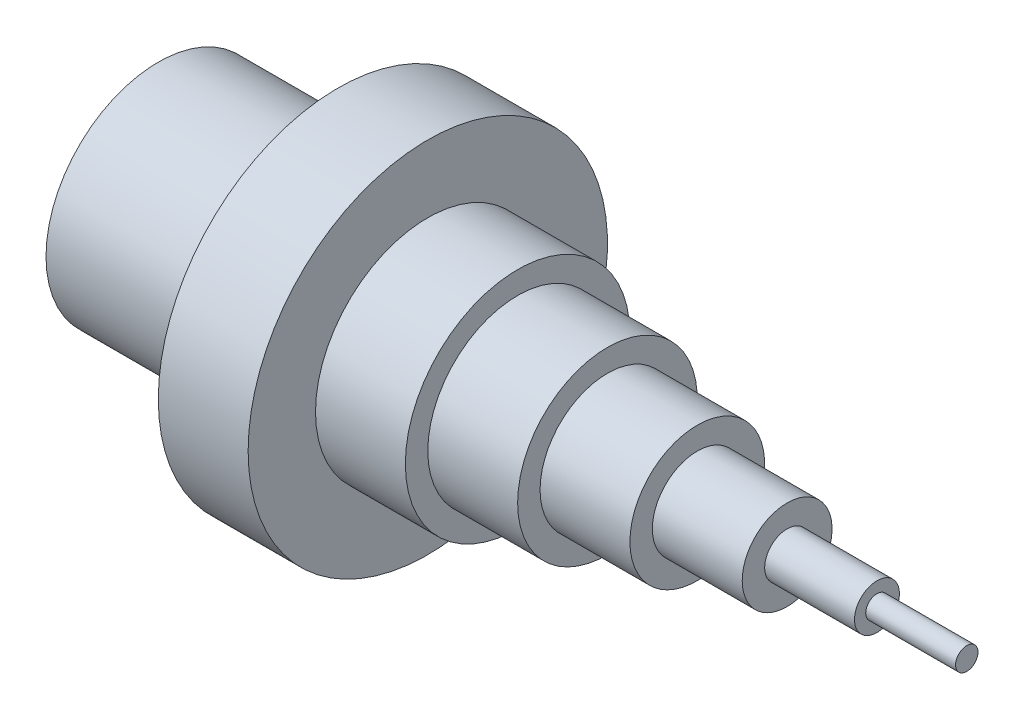
from build123d import *

# Parameters (mm, degrees)
SKETCH2_R          = 20
CUT_EXTRUDE1_DEPTH = 40


with BuildPart() as part:
    # Sketch1 → Revolve1 (revolve)
    with BuildSketch(Plane.XY, mode=Mode.PRIVATE) as revolve1_sk:
        Polygon((0, 0), (0, -25), (40, -25), (40, -40), (60, -40), (60, -25), (80, -25), (80, -20), (100, -20), (100, -15), (120, -15), (120, -10), (140, -10), (140, -5), (160, -5), (160, -2.5), (180, -2.5), (180, 0), align=None)
    revolve(revolve1_sk.sketch.rotate(Axis((0, 0, 0), (1, 0, 0)), 270), axis=Axis((0, 0, 0), (1, 0, 0)))  # turned: the seam where the file's is

    # Sketch2 → Cut-Extrude1 (cut)
    with BuildSketch(Plane.ZY):
        Circle(SKETCH2_R)
    extrude(amount=-CUT_EXTRUDE1_DEPTH, mode=Mode.SUBTRACT)


solid = part.part
